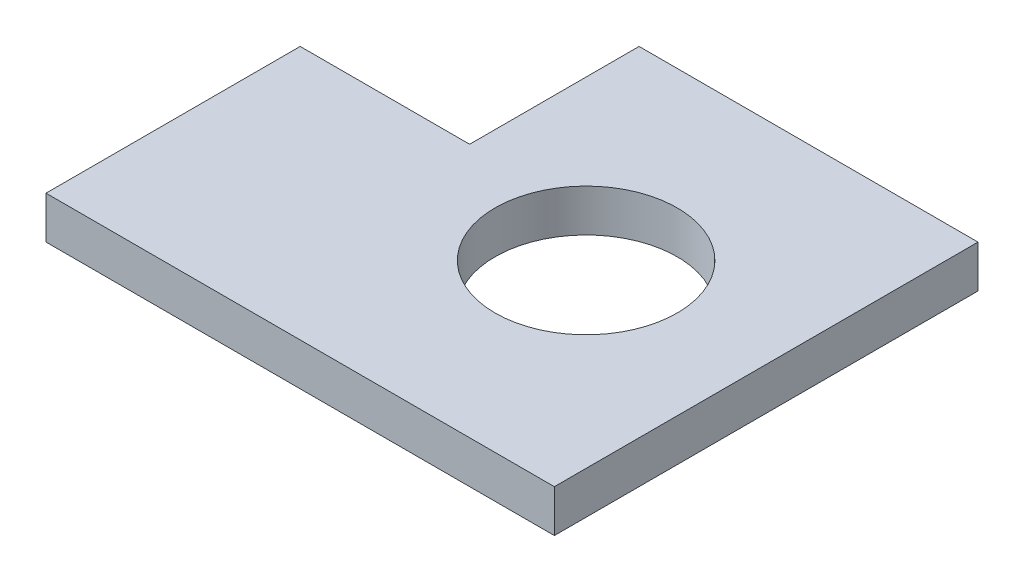
from build123d import *

# Parameters (mm, degrees)
SKETCH_1_R      = 21.5
EXTRUDE_1_DEPTH = 10


with BuildPart() as part:
    # Эскиз1 → Бобышка-Вытянуть1 (new body)
    with BuildSketch(Plane(origin=(0, 0, 0), x_dir=(1, 0, 0), z_dir=(0, 1, 0))):
        Polygon((0, 0), (120, 0), (120, 100), (40, 100), (40, 60), (0, 60), align=None)
        with Locations((77.5, 50)):
            Circle(SKETCH_1_R, mode=Mode.SUBTRACT)
    extrude(amount=EXTRUDE_1_DEPTH)


solid = part.part
